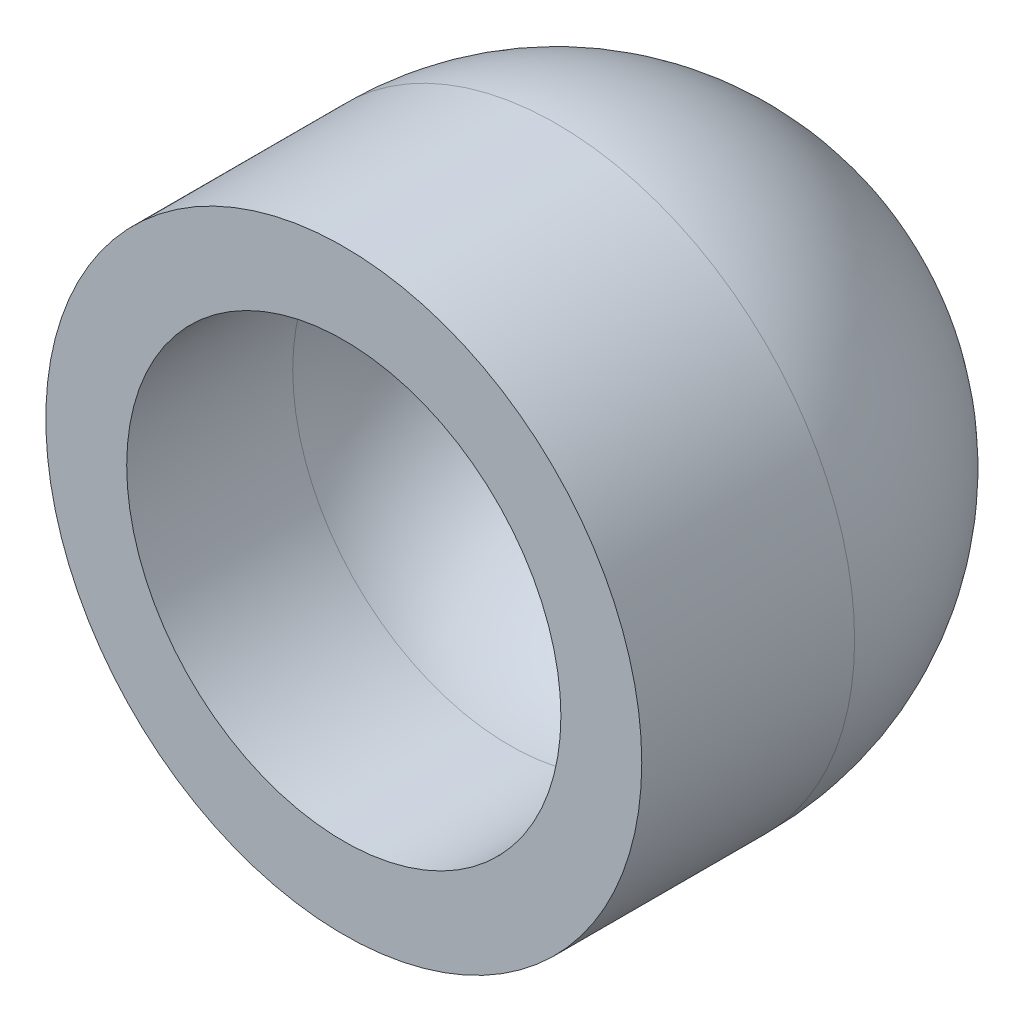
from build123d import *


with BuildPart() as part:
    # Sketch1 → Revolve1 (revolve)
    with BuildSketch(Plane(origin=(0, 0, 0), x_dir=(1, 0, 0), z_dir=(0, 1, 0))):
        with BuildLine():
            Line((0, 0), (0, 3.81))
            ThreePointArc((0, 3.81), (6.286179285, 1.206179285), (8.89, -5.08))
            Line((8.89, -5.08), (8.89, -11.43))
            Line((8.89, -11.43), (6.477, -11.43))
            Line((6.477, -11.43), (6.477, -6.477))
            ThreePointArc((6.477, -6.477), (4.579930622, -1.897069378), (0, 0))
        make_face()
    revolve(axis=Axis((0, 0, 0), (0, 0, -1)))


solid = part.part
